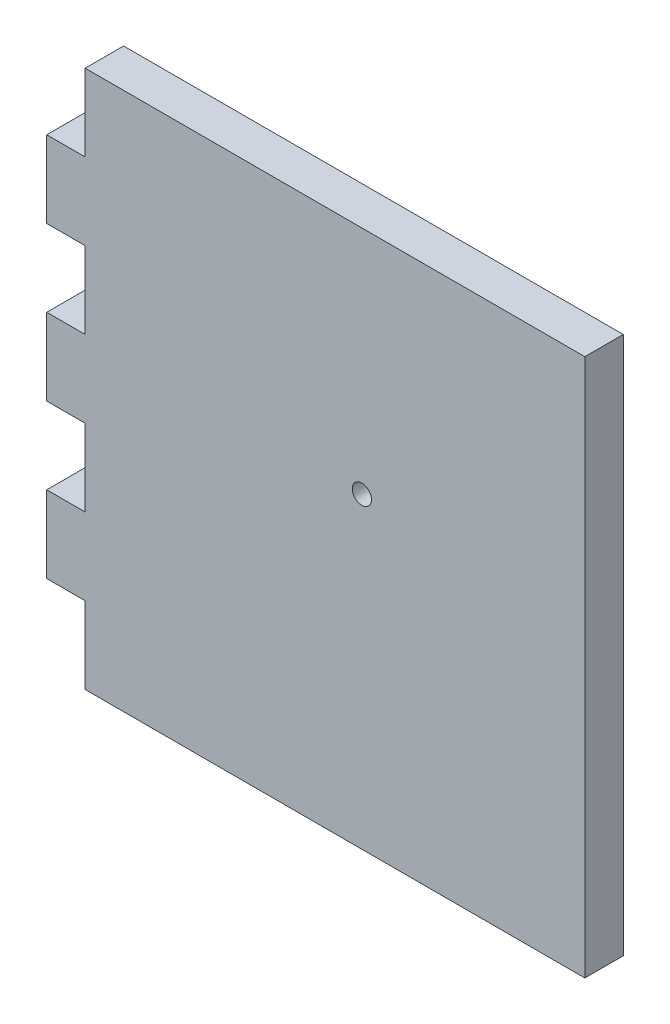
from build123d import *

# Parameters (mm, degrees)
SKETCH1_W           = 177.8
SKETCH1_H           = 177.8
BOSS_EXTRUDE1_DEPTH = 12.7
SKETCH2_R           = 3.175
CUT_EXTRUDE3_DEPTH  = 13.7
SKETCH4_W           = 12.7
SKETCH4_H           = 25.4
CUT_EXTRUDE4_DEPTH  = 13.7


with BuildPart() as part:
    # Sketch1 → Boss-Extrude1 (new body)
    with BuildSketch(Plane.XY):
        with Locations((88.9, -88.9)):
            Rectangle(SKETCH1_W, SKETCH1_H)
    extrude(amount=BOSS_EXTRUDE1_DEPTH)

    # Sketch2 → Cut-Extrude3 (cut, through all)
    with BuildSketch(Plane.XY.offset(12.7)):
        with Locations((104.14, -76.2)):
            Circle(SKETCH2_R)
    extrude(amount=-CUT_EXTRUDE3_DEPTH, mode=Mode.SUBTRACT)

    # Sketch4 → Cut-Extrude4 (cut, through all)
    with BuildSketch(Plane.XY.offset(12.7)):
        with Locations((6.35, -12.7)):
            Rectangle(SKETCH4_W, SKETCH4_H)
        with Locations((6.35, -63.5)):
            Rectangle(SKETCH4_W, SKETCH4_H)
        with Locations((6.35, -114.3)):
            Rectangle(SKETCH4_W, SKETCH4_H)
        with Locations((6.35, -165.1)):
            Rectangle(SKETCH4_W, SKETCH4_H)
    extrude(amount=-CUT_EXTRUDE4_DEPTH, mode=Mode.SUBTRACT)


solid = part.part
